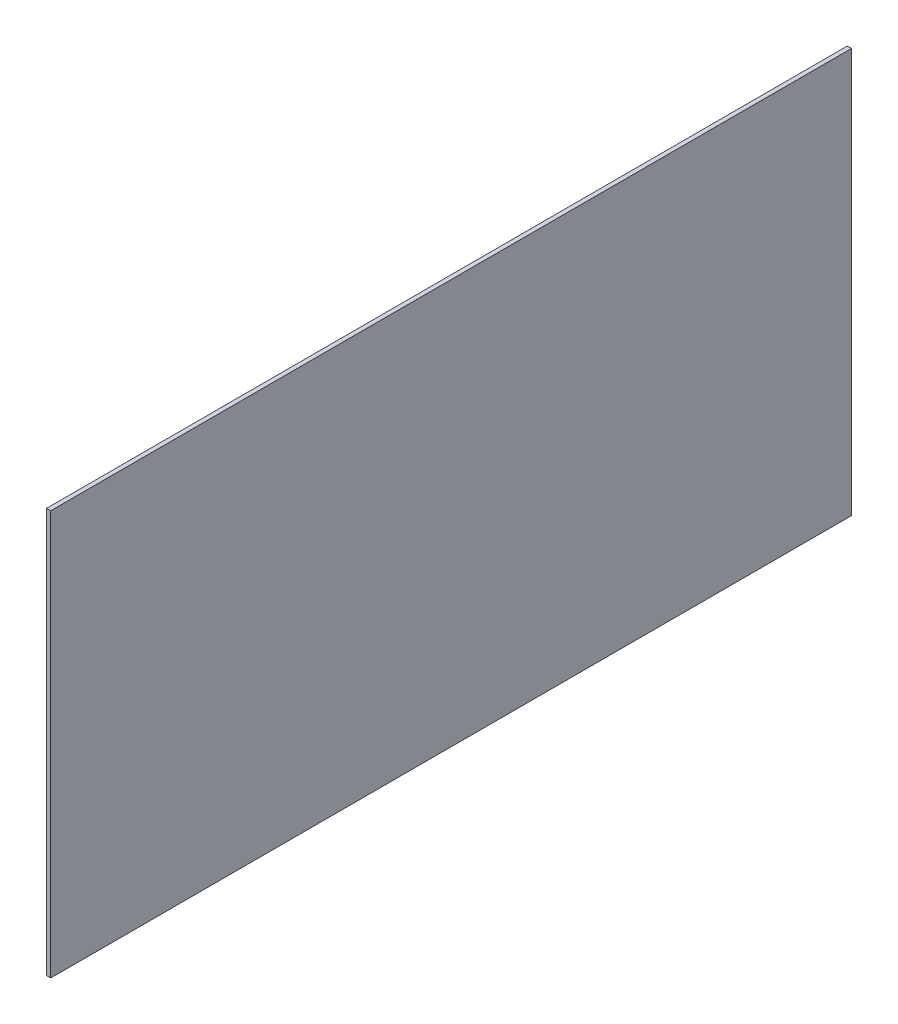
from build123d import *

# Parameters (mm, degrees)
SKETCH1_W           = 609.6
SKETCH1_H           = 304.8
BOSS_EXTRUDE1_DEPTH = 3.175
SKETCH2_W           = 3.175
SKETCH2_H           = 304.8
CUT_EXTRUDE1_DEPTH  = 6.35


with BuildPart() as part:
    # Sketch1 → Boss-Extrude1 (new body)
    with BuildSketch(Plane(origin=(0, 0, 0), x_dir=(0, 0, -1), z_dir=(1, 0, 0))):
        Rectangle(SKETCH1_W, SKETCH1_H)
    extrude(amount=BOSS_EXTRUDE1_DEPTH)

    # Sketch2 → Cut-Extrude1 (cut)
    with BuildSketch(Plane(origin=(0, 0, -304.8), x_dir=(-1, 0, 0), z_dir=(0, 0, -1))):
        with Locations((-1.5875, 0)):
            Rectangle(SKETCH2_W, SKETCH2_H)
    extrude(amount=-CUT_EXTRUDE1_DEPTH, mode=Mode.SUBTRACT)


solid = part.part
